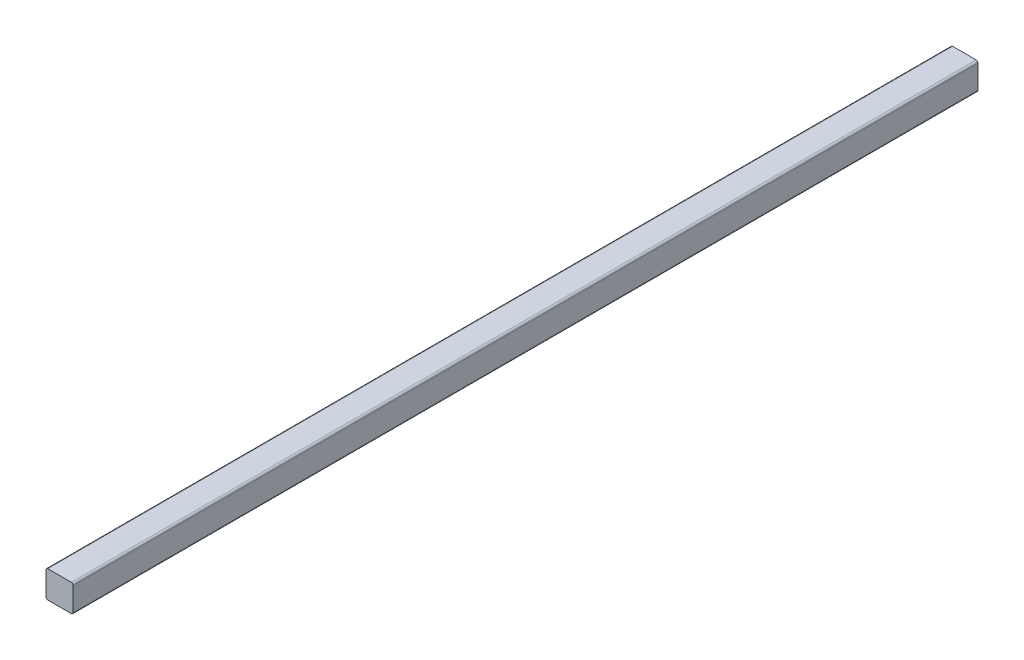
from build123d import *

# Parameters (mm, degrees)
BOSS_EXTRUDE1_DEPTH = 1000


with BuildPart() as part:
    # Sketch3 → Boss-Extrude1 (new body)
    with BuildSketch(Plane.XY):
        with BuildLine():
            Line((2, 0), (28, 0))
            ThreePointArc((28, 0), (29.414213562, 0.585786438), (30, 2))
            Line((30, 2), (30, 28))
            ThreePointArc((30, 28), (29.414213562, 29.414213562), (28, 30))
            Line((28, 30), (2, 30))
            ThreePointArc((2, 30), (0.585786438, 29.414213562), (0, 28))
            Line((0, 28), (0, 2))
            ThreePointArc((0, 2), (0.585786438, 0.585786438), (2, 0))
        make_face()
    extrude(amount=BOSS_EXTRUDE1_DEPTH)


solid = part.part
